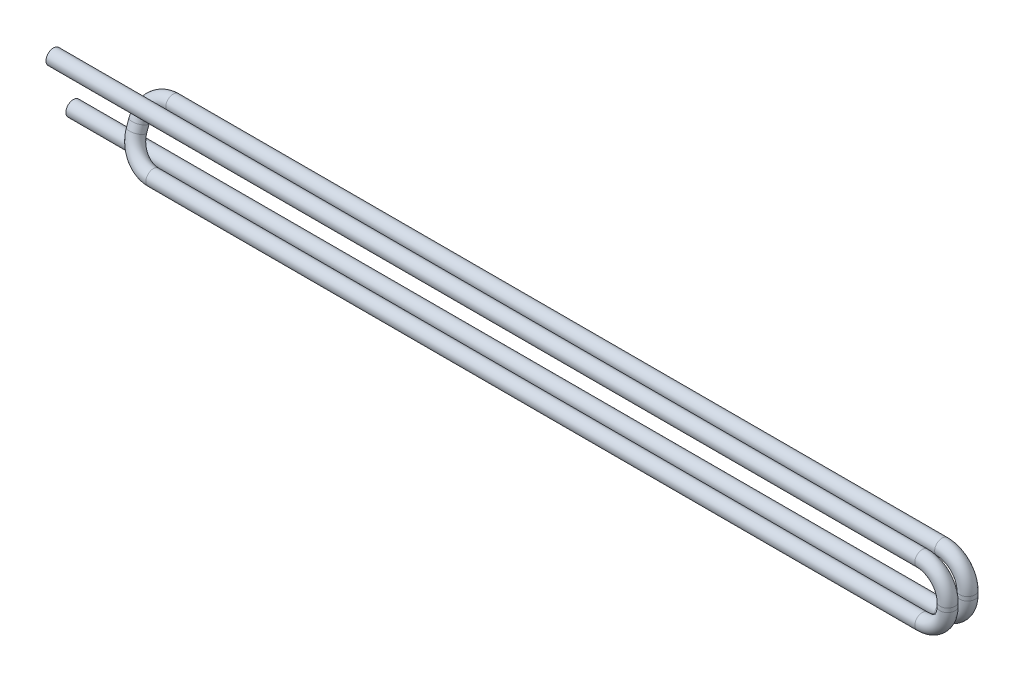
from build123d import *

# Parameters (mm, degrees)
SKETCH5_R = 0.3


with BuildPart() as part:
    # Sweep4: sweep along a curve in space
    with BuildLine() as sweep4_path:
        Line((-36, 0, 0), (-1.021255708, 0, 0))
        ThreePointArc((-1.021255708, 0, 0), (-0.299118872, 0.299118872, 0), (0, 1.021255708, 0))
        Line((0, 1.021255708, 0), (0, 1.178744292, 0))
        ThreePointArc((-1.021255708, 2.2, 0), (-0.299118872, 1.900881128, 0), (0, 1.178744292, 0))
        Line((-1.021255708, 2.2, 0), (-31.978744292, 2.2, 0))
        ThreePointArc((-31.978744292, 2.2, 0), (-32.700881128, 1.918890052, 0.102221799), (-33, 1.240230602, 0.349007054))
        Line((-33, 1.240230602, 0.349007054), (-33, 0.959769398, 0.450992946))
        ThreePointArc((-33, 0.959769398, 0.450992946), (-32.700881128, 0.281109948, 0.6977782), (-31.978744292, 0, 0.8))
        Line((-31.978744292, 0, 0.8), (-1.021255708, 0, 0.8))
        ThreePointArc((-1.021255708, 0, 0.8), (-0.299118872, 0.299118872, 0.8), (0, 1.021255708, 0.8))
        Line((0, 1.021255708, 0.8), (0, 1.178744292, 0.8))
        ThreePointArc((0, 1.178744292, 0.8), (-0.299118872, 1.900881128, 0.8), (-1.021255708, 2.2, 0.8))
        Line((-1.021255708, 2.2, 0.8), (-36, 2.2, 0.8))
    # Sketch5 → Sweep4 (sweep)
    with BuildSketch(Plane(origin=(-36, 0, 0), x_dir=(0, 0, -1), z_dir=(1, 0, 0))):
        Circle(SKETCH5_R)
    sweep(path=sweep4_path.line)


solid = part.part
